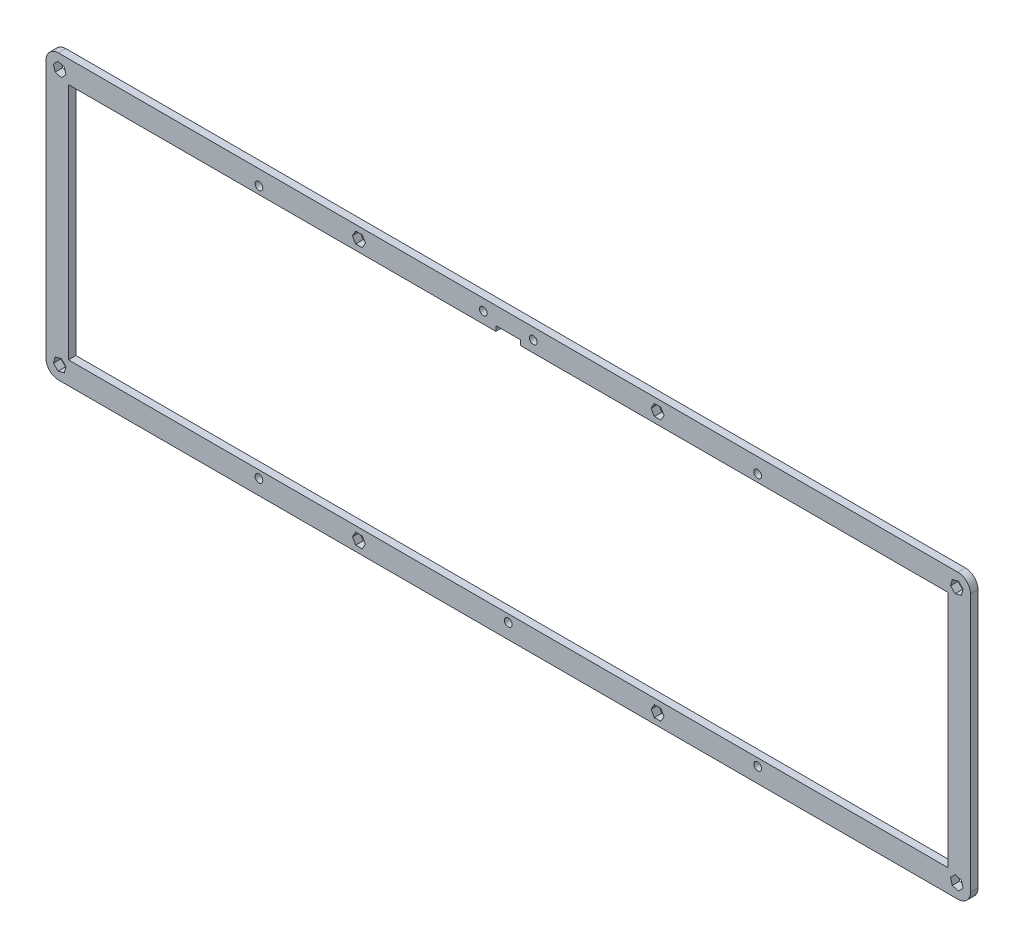
from build123d import *

# Parameters (mm, degrees)
MODEL_R             = 1.55
BOSS_EXTRUDE1_DEPTH = 3


with BuildPart() as part:
    # Model → Boss-Extrude1 (new body)
    with BuildSketch(Plane.XY):
        with BuildLine():
            Line((0, 108.6), (0, 5))
            ThreePointArc((0, 5), (1.464466094, 1.464466094), (5, 0))
            Line((5, 0), (365.775, 0))
            ThreePointArc((365.775, 0), (369.310533906, 1.464466094), (370.775, 5))
            Line((370.775, 5), (370.775, 108.6))
            ThreePointArc((370.775, 108.6), (369.310533906, 112.135533906), (365.775, 113.6))
            Line((365.775, 113.6), (5, 113.6))
            ThreePointArc((5, 113.6), (1.464466094, 112.135533906), (0, 108.6))
        make_face()
        with Locations((195.3875, 109.1)):
            Circle(MODEL_R, mode=Mode.SUBTRACT)
        with Locations((175.3875, 109.1)):
            Circle(MODEL_R, mode=Mode.SUBTRACT)
        with Locations((85.3875, 107.6)):
            Circle(MODEL_R, mode=Mode.SUBTRACT)
        with Locations((285.3875, 107.6)):
            Circle(MODEL_R, mode=Mode.SUBTRACT)
        with Locations((85.3875, 6)):
            Circle(MODEL_R, mode=Mode.SUBTRACT)
        with Locations((185.3875, 6)):
            Circle(MODEL_R, mode=Mode.SUBTRACT)
        with Locations((285.3875, 6)):
            Circle(MODEL_R, mode=Mode.SUBTRACT)
        Polygon((9, 9), (361.775, 9), (361.775, 104.6), (190.3875, 104.6), (190.3875, 106.6), (180.3875, 106.6), (180.3875, 104.6), (9, 104.6), align=None, mode=Mode.SUBTRACT)
        Polygon((365.947431604, 110.609548911), (367.784548911, 108.772431604), (367.112117307, 106.262882693), (364.602568396, 105.590451089), (362.765451089, 107.427568396), (363.437882693, 109.937117307), align=None, mode=Mode.SUBTRACT)
        Polygon((4.827568396, 110.609548911), (2.990451089, 108.772431604), (3.662882693, 106.262882693), (6.172431604, 105.590451089), (8.009548911, 107.427568396), (7.337117307, 109.937117307), align=None, mode=Mode.SUBTRACT)
        Polygon((365.947431604, 2.990451089), (367.784548911, 4.827568396), (367.112117307, 7.337117307), (364.602568396, 8.009548911), (362.765451089, 6.172431604), (363.437882693, 3.662882693), align=None, mode=Mode.SUBTRACT)
        Polygon((126.799038106, 2.25), (124.200961894, 2.25), (122.901923789, 4.5), (124.200961894, 6.75), (126.799038106, 6.75), (128.098076211, 4.5), align=None, mode=Mode.SUBTRACT)
        Polygon((4.827568396, 2.990451089), (2.990451089, 4.827568396), (3.662882693, 7.337117307), (6.172431604, 8.009548911), (8.009548911, 6.172431604), (7.337117307, 3.662882693), align=None, mode=Mode.SUBTRACT)
        Polygon((126.799038106, 111.35), (124.200961894, 111.35), (122.901923789, 109.1), (124.200961894, 106.85), (126.799038106, 106.85), (128.098076211, 109.1), align=None, mode=Mode.SUBTRACT)
        Polygon((243.975961894, 2.25), (246.574038106, 2.25), (247.873076211, 4.5), (246.574038106, 6.75), (243.975961894, 6.75), (242.676923789, 4.5), align=None, mode=Mode.SUBTRACT)
        Polygon((243.975961894, 111.35), (246.574038106, 111.35), (247.873076211, 109.1), (246.574038106, 106.85), (243.975961894, 106.85), (242.676923789, 109.1), align=None, mode=Mode.SUBTRACT)
    extrude(amount=BOSS_EXTRUDE1_DEPTH)


solid = part.part
